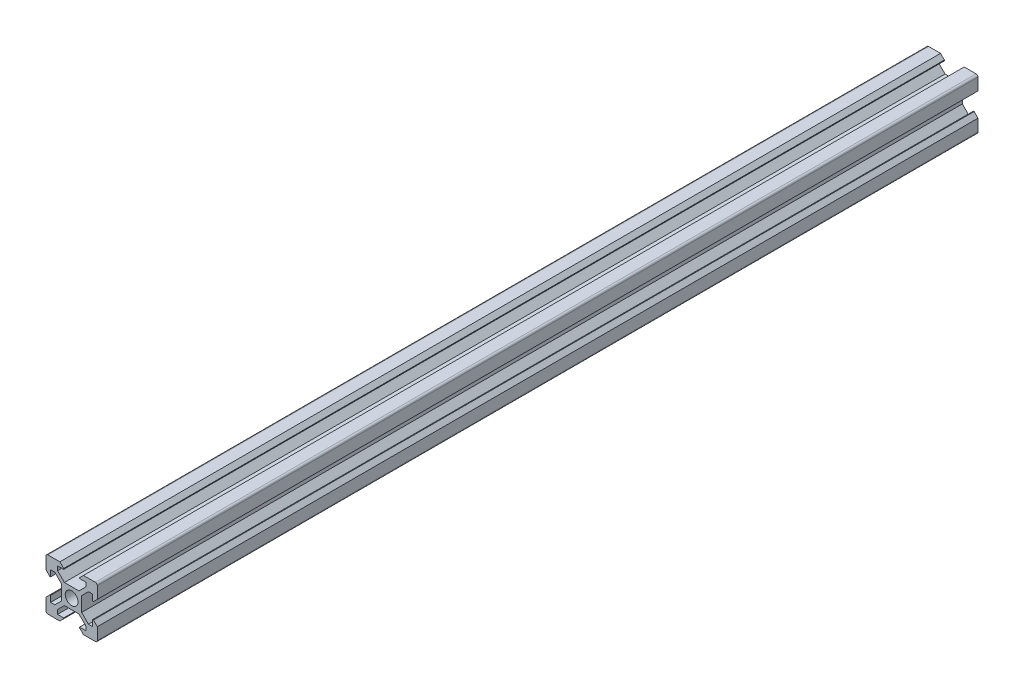
from build123d import *

# Parameters (mm, degrees)
CROQUIS1_R              = 2.5
SALIENTE_EXTRUIR1_DEPTH = 343.37


with BuildPart() as part:
    # Croquis1 → Saliente-Extruir1 (new body)
    with BuildSketch(Plane.XY):
        with BuildLine():
            Line((-4.6, 10), (-3.1, 8.5))
            Line((-3.1, 8.5), (-3.1, 8.2))
            Line((-3.1, 8.2), (-5.5, 8.2))
            Line((-5.5, 8.2), (-5.5, 6.560660172))
            Line((-5.5, 6.560660172), (-2.84, 3.900660172))
            Line((-2.84, 3.900660172), (0, 3.900660172))
            Line((0, 3.900660172), (2.84, 3.900660172))
            Line((2.84, 3.900660172), (5.5, 6.560660172))
            Line((5.5, 6.560660172), (5.5, 8.2))
            Line((5.5, 8.2), (3.1, 8.2))
            Line((3.1, 8.2), (3.1, 8.5))
            Line((3.1, 8.5), (4.6, 10))
            Line((4.6, 10), (9.25, 10))
            ThreePointArc((9.25, 10), (9.780330086, 9.780330086), (10, 9.25))
            Line((10, 9.25), (10, 4.6))
            Line((10, 4.6), (8.5, 3.1))
            Line((8.5, 3.1), (8.2, 3.1))
            Line((8.2, 3.1), (8.2, 5.5))
            Line((8.2, 5.5), (6.560660172, 5.5))
            Line((6.560660172, 5.5), (3.900660172, 2.84))
            Line((3.900660172, 2.84), (3.900660172, 0))
            Line((3.900660172, 0), (3.900660172, -2.84))
            Line((3.900660172, -2.84), (6.560660172, -5.5))
            Line((6.560660172, -5.5), (8.2, -5.5))
            Line((8.2, -5.5), (8.2, -3.1))
            Line((8.2, -3.1), (8.5, -3.1))
            Line((8.5, -3.1), (10, -4.6))
            Line((10, -4.6), (10, -9.25))
            ThreePointArc((10, -9.25), (9.780330086, -9.780330086), (9.25, -10))
            Line((9.25, -10), (4.6, -10))
            Line((4.6, -10), (3.1, -8.5))
            Line((3.1, -8.5), (3.1, -8.2))
            Line((3.1, -8.2), (5.5, -8.2))
            Line((5.5, -8.2), (5.5, -6.560660172))
            Line((5.5, -6.560660172), (2.84, -3.900660172))
            Line((2.84, -3.900660172), (0, -3.900660172))
            Line((0, -3.900660172), (-2.84, -3.900660172))
            Line((-2.84, -3.900660172), (-5.5, -6.560660172))
            Line((-5.5, -6.560660172), (-5.5, -8.2))
            Line((-5.5, -8.2), (-3.1, -8.2))
            Line((-3.1, -8.2), (-3.1, -8.5))
            Line((-3.1, -8.5), (-4.6, -10))
            Line((-4.6, -10), (-9.25, -10))
            ThreePointArc((-9.25, -10), (-9.780330086, -9.780330086), (-10, -9.25))
            Line((-10, -9.25), (-10, -4.6))
            Line((-10, -4.6), (-8.5, -3.1))
            Line((-8.5, -3.1), (-8.2, -3.1))
            Line((-8.2, -3.1), (-8.2, -5.5))
            Line((-8.2, -5.5), (-6.560660172, -5.5))
            Line((-6.560660172, -5.5), (-3.900660172, -2.84))
            Line((-3.900660172, -2.84), (-3.900660172, 0))
            Line((-3.900660172, 0), (-3.900660172, 2.84))
            Line((-3.900660172, 2.84), (-6.560660172, 5.5))
            Line((-6.560660172, 5.5), (-8.2, 5.5))
            Line((-8.2, 5.5), (-8.2, 3.1))
            Line((-8.2, 3.1), (-8.5, 3.1))
            Line((-8.5, 3.1), (-10, 4.6))
            Line((-10, 4.6), (-10, 9.25))
            ThreePointArc((-10, 9.25), (-9.780330086, 9.780330086), (-9.25, 10))
            Line((-9.25, 10), (-4.6, 10))
        make_face()
        Circle(CROQUIS1_R, mode=Mode.SUBTRACT)
    extrude(amount=SALIENTE_EXTRUIR1_DEPTH)


solid = part.part
